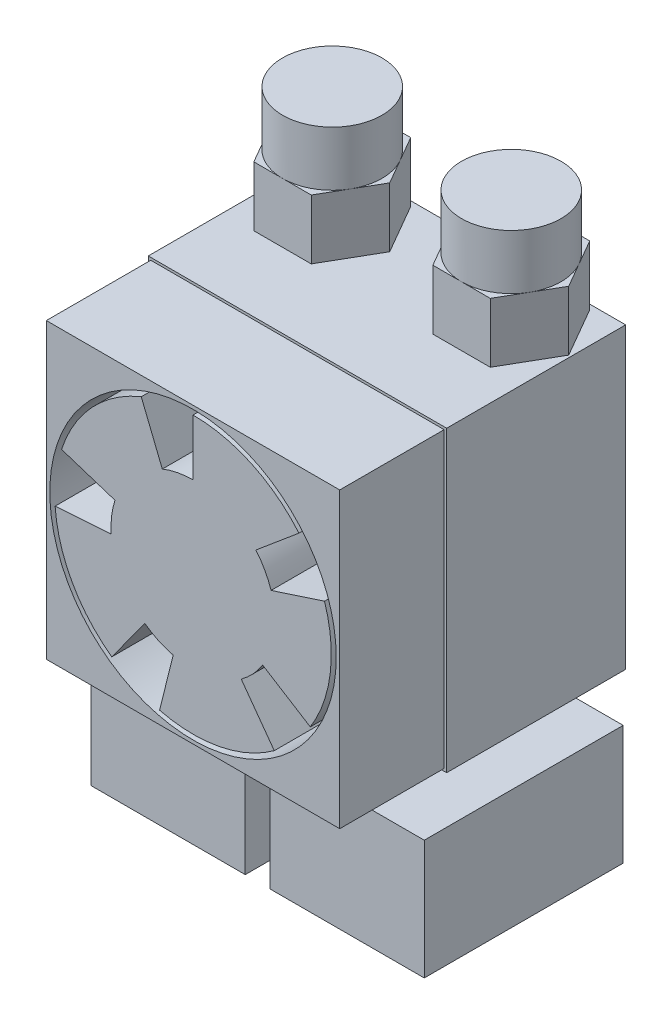
from build123d import *

# Parameters (mm, degrees)
ESBO_O1_W                = 30
ESBO_O1_H                = 30
RESSALTO_EXTRUS_O1_DEPTH = 28.5
ESBO_O2_R                = 1.6
CORTE_EXTRUS_O1_DEPTH    = 5
ESBO_O3_R                = 2.25
RESSALTO_EXTRUS_O2_DEPTH = 3
ESBO_O4_W                = 15.5
ESBO_O4_H                = 20
RESSALTO_EXTRUS_O3_DEPTH = 12
ESBO_O5_R                = 2.25
RESSALTO_EXTRUS_O4_DEPTH = 5
RESSALTO_EXTRUS_O4_TAPER = 22
ESBO_O6_W                = 30
ESBO_O6_H                = 30
ESBO_O6_W_2              = 29.5
ESBO_O6_H_2              = 29.5
ESBO_O6_R                = 14.4
CORTE_EXTRUS_O2_DEPTH    = 10.5
RESSALTO_EXTRUS_O5_DEPTH = 6
ESBO_O10_R               = 5
RESSALTO_EXTRUS_O6_DEPTH = 5.5


with BuildPart() as part:
    # Esboço1 → Ressalto-extrusão1 (new body)
    with BuildSketch(Plane.XY):
        Rectangle(ESBO_O1_W, ESBO_O1_H)
    extrude(amount=RESSALTO_EXTRUS_O1_DEPTH)

    # Esboço2 → Corte-extrusão1 (cut)
    with BuildSketch(Plane(origin=(0, 0, 0), x_dir=(-1, 0, 0), z_dir=(0, 0, -1))):
        with Locations((4.5, 5)):
            Circle(ESBO_O2_R)
        with Locations((-4.5, 5)):
            Circle(ESBO_O2_R)
        with Locations((0, -4.8)):
            Circle(ESBO_O2_R)
    extrude(amount=-CORTE_EXTRUS_O1_DEPTH, mode=Mode.SUBTRACT)

    # Esboço3 → Ressalto-extrusão2 (add)
    with BuildSketch(Plane.XZ.offset(15)):
        with Locations((-9, 5.5)):
            Circle(ESBO_O3_R)
        with Locations((9, 5.5)):
            Circle(ESBO_O3_R)
    extrude(amount=RESSALTO_EXTRUS_O2_DEPTH)

    # Esboço4 → Ressalto-extrusão3 (add)
    with BuildSketch(Plane.XZ.offset(18)):
        with Locations((-9, 12)):
            Rectangle(ESBO_O4_W, ESBO_O4_H)
        with Locations((9, 12)):
            Rectangle(ESBO_O4_W, ESBO_O4_H)
    extrude(amount=RESSALTO_EXTRUS_O3_DEPTH)

    # Esboço5 → Ressalto-extrusão4 (add)
    with BuildSketch(Plane.XZ.offset(30)):
        with Locations((9, 5.5)):
            Circle(ESBO_O5_R)
        with Locations((-9, 5.5)):
            Circle(ESBO_O5_R)
    extrude(amount=RESSALTO_EXTRUS_O4_DEPTH, taper=RESSALTO_EXTRUS_O4_TAPER)

    # Esboço6 → Corte-extrusão2 (cut)
    with BuildSketch(Plane.XY.offset(28.5)):
        Rectangle(ESBO_O6_W, ESBO_O6_H)
        Rectangle(ESBO_O6_W_2, ESBO_O6_H_2, mode=Mode.SUBTRACT)
        Circle(ESBO_O6_R)
        with BuildLine():
            ThreePointArc((-7.846216259, 2.549390204), (-8.188505751, 1.005422083), (-8.229903415, -0.575490908))
            Line((-8.229903415, -0.575490908), (-13.866140299, -0.969614985))
            ThreePointArc((-13.866140299, -0.969614985), (-12.157213929, -6.738853721), (-8.170215007, -11.245336222))
            Line((-8.170215007, -11.245336222), (-4.849228331, -6.674390204))
            ThreePointArc((-4.849228331, -6.674390204), (-3.486600659, -7.477039243), (-1.995855639, -8.004939742))
            Line((-1.995855639, -8.004939742), (-3.362714349, -13.487110595))
            ThreePointArc((-3.362714349, -13.487110595), (2.652245036, -13.64461785), (8.170215007, -11.245336222))
            Line((8.170215007, -11.245336222), (4.849228331, -6.674390204))
            ThreePointArc((4.849228331, -6.674390204), (6.033668038, -5.626486471), (6.996396793, -4.37183393))
            Line((6.996396793, -4.37183393), (11.787868537, -7.365877773))
            ThreePointArc((11.787868537, -7.365877773), (13.796391508, -1.693983873), (13.219685577, 4.295336222))
            Line((13.219685577, 4.295336222), (7.846216259, 2.549390204))
            ThreePointArc((7.846216259, 2.549390204), (7.215612584, 3.999679367), (6.319866656, 5.30299778))
            Line((6.319866656, 5.30299778), (10.648017759, 8.934747775))
            ThreePointArc((10.648017759, 8.934747775), (5.874393838, 12.59767824), (0, 13.9))
            Line((0, 13.9), (0, 8.25))
            ThreePointArc((0, 8.25), (-1.574174212, 8.098424263), (-3.090504396, 7.6492668))
            Line((-3.090504396, 7.6492668), (-5.207031648, 12.887855578))
            ThreePointArc((-5.207031648, 12.887855578), (-10.165816453, 9.479777205), (-13.219685577, 4.295336222))
            Line((-13.219685577, 4.295336222), (-7.846216259, 2.549390204))
        make_face(mode=Mode.SUBTRACT)
    extrude(amount=-CORTE_EXTRUS_O2_DEPTH, mode=Mode.SUBTRACT)

    # Esboço9 → Ressalto-extrusão5 (add)
    with BuildSketch(Plane(origin=(0, 15, 0), x_dir=(1, 0, 0), z_dir=(0, 1, 0))):
        Polygon((14.773502692, -5.5), (11.886751346, -0.5), (6.113248654, -0.5), (3.226497308, -5.5), (6.113248654, -10.5), (11.886751346, -10.5), align=None)
        Polygon((-3.226497308, -5.5), (-6.113248654, -0.5), (-11.886751346, -0.5), (-14.773502692, -5.5), (-11.886751346, -10.5), (-6.113248654, -10.5), align=None)
    extrude(amount=RESSALTO_EXTRUS_O5_DEPTH)

    # Esboço10 → Ressalto-extrusão6 (add)
    with BuildSketch(Plane(origin=(0, 21, 0), x_dir=(1, 0, 0), z_dir=(0, 1, 0))):
        with Locations((-9, -5.5)):
            Circle(ESBO_O10_R)
        with Locations((9, -5.5)):
            Circle(ESBO_O10_R)
    extrude(amount=RESSALTO_EXTRUS_O6_DEPTH)


solid = part.part
